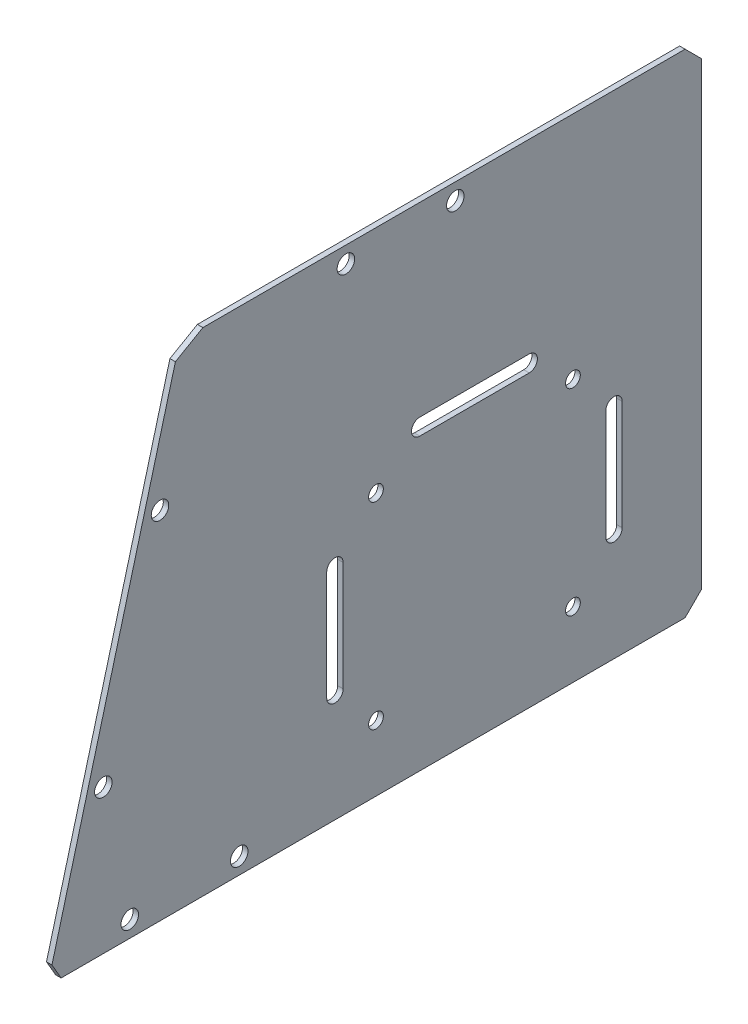
from build123d import *

# Parameters (mm, degrees)
SKETCH_1_W               = 60
SKETCH_1_H               = 44
SKETCH_1_R               = 1.6
EXTRUDE_1_DEPTH          = 1
SKETCH_2_W               = 134.5
SKETCH_2_H               = 90
EXTRUDE_2_DEPTH          = 1
CUT_EXTRUDE_1_DEPTH      = 2
SKETCH_4_R               = 1.6
CUT_EXTRUDE_2_DEPTH      = 2
SKETCH_5_R               = 1.35
CUT_EXTRUDE_3_DEPTH      = 2
SKETCH_6_W               = 15
SKETCH_6_H               = 90
CUT_EXTRUDE_4_DEPTH      = 1
CUT_EXTRUDE_4_DEPTH_BACK = 2
SKETCH_7_W               = 9
SKETCH_7_H               = 22.5
CUT_EXTRUDE_5_DEPTH      = 2
FILLET_1_R               = 2
CUT_EXTRUDE_6_DEPTH      = 2
CUT_EXTRUDE_7_DEPTH      = 2
CHAMFER_2_SIZE           = 3
CHAMFER_2_EDGE_2_SIZE    = 3
CHAMFER_2_EDGE_3_SIZE2   = 3
CHAMFER_2_EDGE_3_SIZE    = 2.449489743
CHAMFER_2_EDGE_4_SIZE2   = 4.242640687
CHAMFER_2_EDGE_4_SIZE    = 3


with BuildPart() as part:
    # 草图1 → 凸台-拉伸1 (new body)
    with BuildSketch(Plane(origin=(0, 0, 0), x_dir=(0, 0, -1), z_dir=(1, 0, 0))):
        with Locations((18, -14.5)):
            Rectangle(SKETCH_1_W, SKETCH_1_H)
        Circle(SKETCH_1_R, mode=Mode.SUBTRACT)
        with Locations((17, 0)):
            Circle(SKETCH_1_R, mode=Mode.SUBTRACT)
        with Locations((0, -30.5)):
            Circle(SKETCH_1_R, mode=Mode.SUBTRACT)
        with Locations((17, -30.5)):
            Circle(SKETCH_1_R, mode=Mode.SUBTRACT)
        with Locations((31.5, -30.5)):
            Circle(SKETCH_1_R, mode=Mode.SUBTRACT)
    extrude(amount=EXTRUDE_1_DEPTH)

    # 草图2 → 凸台-拉伸2 (add)
    with BuildSketch(Plane(origin=(1, 0, 0), x_dir=(0, 0, -1), z_dir=(1, 0, 0))):
        with Locations((-19.25, 52.5)):
            Rectangle(SKETCH_2_W, SKETCH_2_H)
    extrude(amount=-EXTRUDE_2_DEPTH)

    # 草图3 → 切除-拉伸1 (cut, through all)
    with BuildSketch(Plane.ZY):
        Polygon((86.5, 7.5), (62.384572681, 97.5), (86.5, 97.5), align=None)
    extrude(amount=-CUT_EXTRUDE_1_DEPTH, mode=Mode.SUBTRACT)

    # 草图4 → 切除-拉伸2 (cut, through all)
    with BuildSketch(Plane.ZY):
        with Locations((71.5, 10.5)):
            Circle(SKETCH_4_R)
        with Locations((51.5, 10.5)):
            Circle(SKETCH_4_R)
        with Locations((12, 94.5)):
            Circle(SKETCH_4_R)
        with Locations((32, 94.5)):
            Circle(SKETCH_4_R)
        with Locations((65.977473951, 72.5)):
            Circle(SKETCH_4_R)
        with Locations((76.330235755, 33.862966948)):
            Circle(SKETCH_4_R)
    extrude(amount=-CUT_EXTRUDE_2_DEPTH, mode=Mode.SUBTRACT)

    # 草图5 → 切除-拉伸3 (cut, through all)
    with BuildSketch(Plane(origin=(1, 0, 0), x_dir=(0, 0, -1), z_dir=(1, 0, 0))):
        with Locations((-26.5, 55.5)):
            Circle(SKETCH_5_R)
        with Locations((9.5, 55.5)):
            Circle(SKETCH_5_R)
        with Locations((9.5, 19.5)):
            Circle(SKETCH_5_R)
        with Locations((-26.5, 19.5)):
            Circle(SKETCH_5_R)
    extrude(amount=-CUT_EXTRUDE_3_DEPTH, mode=Mode.SUBTRACT)

    # 草图6 → 切除-拉伸4 (cut, two sides)
    with BuildSketch(Plane(origin=(1, 0, 0), x_dir=(0, 0, -1), z_dir=(1, 0, 0))) as cut_extrude_4_sk:
        with Locations((40.5, 52.5)):
            Rectangle(SKETCH_6_W, SKETCH_6_H)
    extrude(amount=CUT_EXTRUDE_4_DEPTH, mode=Mode.SUBTRACT)
    extrude(cut_extrude_4_sk.sketch, amount=-CUT_EXTRUDE_4_DEPTH_BACK, mode=Mode.SUBTRACT)

    # 草图7 → 切除-拉伸5 (cut, through all)
    with BuildSketch(Plane(origin=(1, 0, 0), x_dir=(0, 0, -1), z_dir=(1, 0, 0))):
        with Locations((8.5, -15.25)):
            Rectangle(SKETCH_7_W, SKETCH_7_H)
    extrude(amount=-CUT_EXTRUDE_5_DEPTH, mode=Mode.SUBTRACT)

    # 圆角1
    fillet_1_edges = [part.edges().sort_by_distance(p)[0] for p in [
        (0.5, -4, -13),
        (0.5, -26.5, -13),
        (0.5, -26.5, -4),
        (0.5, -4, -4),
    ]]
    fillet(fillet_1_edges, radius=FILLET_1_R)

    # 草图8 → 切除-拉伸6 (cut, through all)
    with BuildSketch(Plane(origin=(1, 0, 0), x_dir=(0, 0, -1), z_dir=(1, 0, 0))):
        Polygon((-12, 7.5), (33, 7.5), (48, 7.5), (48, -36.5), (-12, -36.5), align=None)
    extrude(amount=-CUT_EXTRUDE_6_DEPTH, mode=Mode.SUBTRACT)

    # 草图9 → 切除-拉伸7 (cut, through all)
    with BuildSketch(Plane(origin=(1, 0, 0), x_dir=(0, 0, -1), z_dir=(1, 0, 0))):
        with BuildLine():
            Line((-18.5, 63.5), (1.5, 63.5))
            ThreePointArc((1.5, 63.5), (3, 62), (1.5, 60.5))
            Line((1.5, 60.5), (-18.5, 60.5))
            ThreePointArc((-18.5, 60.5), (-20, 62), (-18.5, 63.5))
        make_face()
        with BuildLine():
            Line((-32.5, 47.5), (-32.5, 27.5))
            ThreePointArc((-32.5, 27.5), (-34, 26), (-35.5, 27.5))
            Line((-35.5, 27.5), (-35.5, 47.5))
            ThreePointArc((-35.5, 47.5), (-34, 49), (-32.5, 47.5))
        make_face()
        with BuildLine():
            Line((15.5, 47.5), (15.5, 27.5))
            ThreePointArc((15.5, 27.5), (17, 26), (18.5, 27.5))
            Line((18.5, 27.5), (18.5, 47.5))
            ThreePointArc((18.5, 47.5), (17, 49), (15.5, 47.5))
        make_face()
    extrude(amount=-CUT_EXTRUDE_7_DEPTH, mode=Mode.SUBTRACT)

    # 倒角2
    chamfer_2_edges = [part.edges().sort_by_distance(p)[0] for p in [
        (0.5, 7.5, -33),
    ]]
    chamfer(chamfer_2_edges, length=CHAMFER_2_SIZE)

    # 倒角2 edge 2
    chamfer_2_edge_2_edges = [part.edges().sort_by_distance(p)[0] for p in [
        (0.5, 97.5, -33),
    ]]
    chamfer(chamfer_2_edge_2_edges, length=CHAMFER_2_EDGE_2_SIZE)

    # 倒角2 edge 3
    chamfer_2_edge_3_edges = [part.edges().sort_by_distance(p)[0] for p in [
        (0.5, 7.5, 86.5),
    ]]
    chamfer(chamfer_2_edge_3_edges, length=CHAMFER_2_EDGE_3_SIZE, length2=CHAMFER_2_EDGE_3_SIZE2)

    # 倒角2 edge 4
    chamfer_2_edge_4_edges = [part.edges().sort_by_distance(p)[0] for p in [
        (0.5, 97.5, 62.384572681),
    ]]
    chamfer(chamfer_2_edge_4_edges, length=CHAMFER_2_EDGE_4_SIZE, length2=CHAMFER_2_EDGE_4_SIZE2)


solid = part.part
